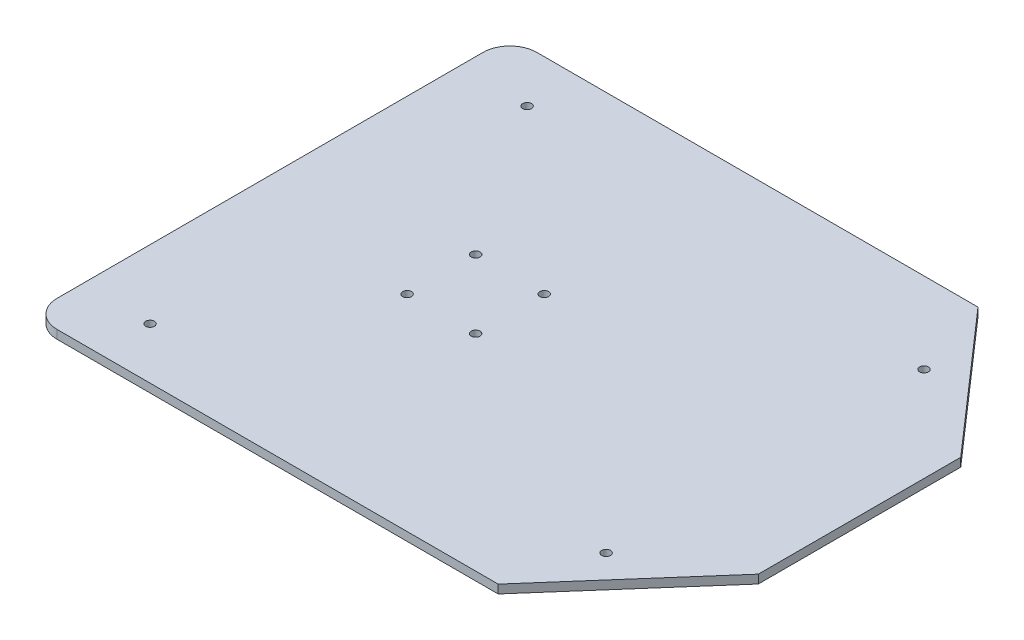
from build123d import *

# Parameters (mm, degrees)
SKETCH1_R           = 1.63195
BOSS_EXTRUDE1_DEPTH = 3.175


with BuildPart() as part:
    # Sketch1 → Boss-Extrude1 (new body)
    with BuildSketch(Plane(origin=(0, 0, 0), x_dir=(1, 0, 0), z_dir=(0, 1, 0))):
        with BuildLine():
            Line((-66.2, 88.9), (97.24, 88.9))
            Line((97.24, 88.9), (142.24, 37.5))
            Line((142.24, 37.5), (142.24, -37.5))
            Line((142.24, -37.5), (97.24, -88.9))
            Line((97.24, -88.9), (-66.2, -88.9))
            ThreePointArc((-66.2, -88.9), (-73.271067812, -85.971067812), (-76.2, -78.9))
            Line((-76.2, -78.9), (-76.2, 78.9))
            ThreePointArc((-76.2, 78.9), (-73.271067812, 85.971067812), (-66.2, 88.9))
        make_face()
        with Locations((-12.7, 12.7)):
            Circle(SKETCH1_R, mode=Mode.SUBTRACT)
        with Locations((12.7, 12.7)):
            Circle(SKETCH1_R, mode=Mode.SUBTRACT)
        with Locations((12.7, -12.7)):
            Circle(SKETCH1_R, mode=Mode.SUBTRACT)
        with Locations((-12.7, -12.7)):
            Circle(SKETCH1_R, mode=Mode.SUBTRACT)
        with Locations((-50.8, 69.85)):
            Circle(SKETCH1_R, mode=Mode.SUBTRACT)
        with Locations((107.24, 58.9)):
            Circle(SKETCH1_R, mode=Mode.SUBTRACT)
        with Locations((107.24, -58.9)):
            Circle(SKETCH1_R, mode=Mode.SUBTRACT)
        with Locations((-50.8, -69.85)):
            Circle(SKETCH1_R, mode=Mode.SUBTRACT)
    extrude(amount=BOSS_EXTRUDE1_DEPTH)


solid = part.part
